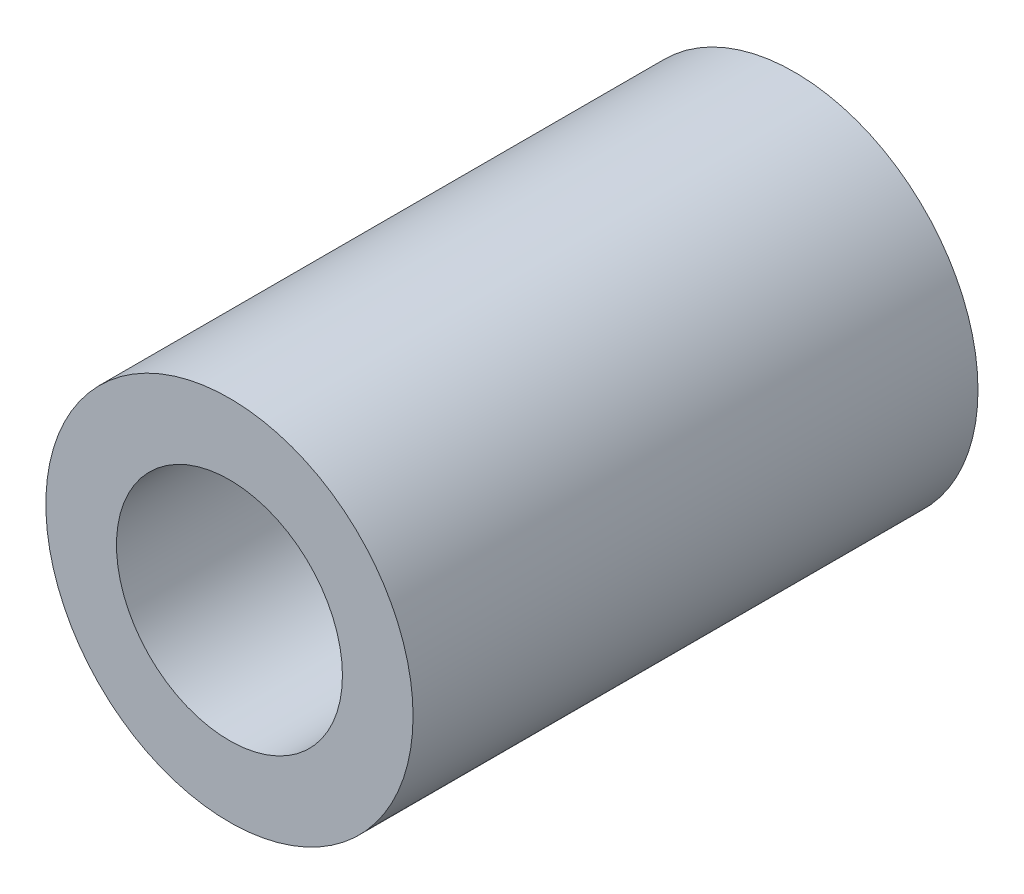
from build123d import *

# Parameters (mm, degrees)
SKETCH1_R           = 3.25
SKETCH1_R_2         = 2
BOSS_EXTRUDE1_DEPTH = 10


with BuildPart() as part:
    # Sketch1 → Boss-Extrude1 (new body)
    with BuildSketch(Plane.XY):
        Circle(SKETCH1_R)
        Circle(SKETCH1_R_2, mode=Mode.SUBTRACT)
    extrude(amount=BOSS_EXTRUDE1_DEPTH)


solid = part.part
